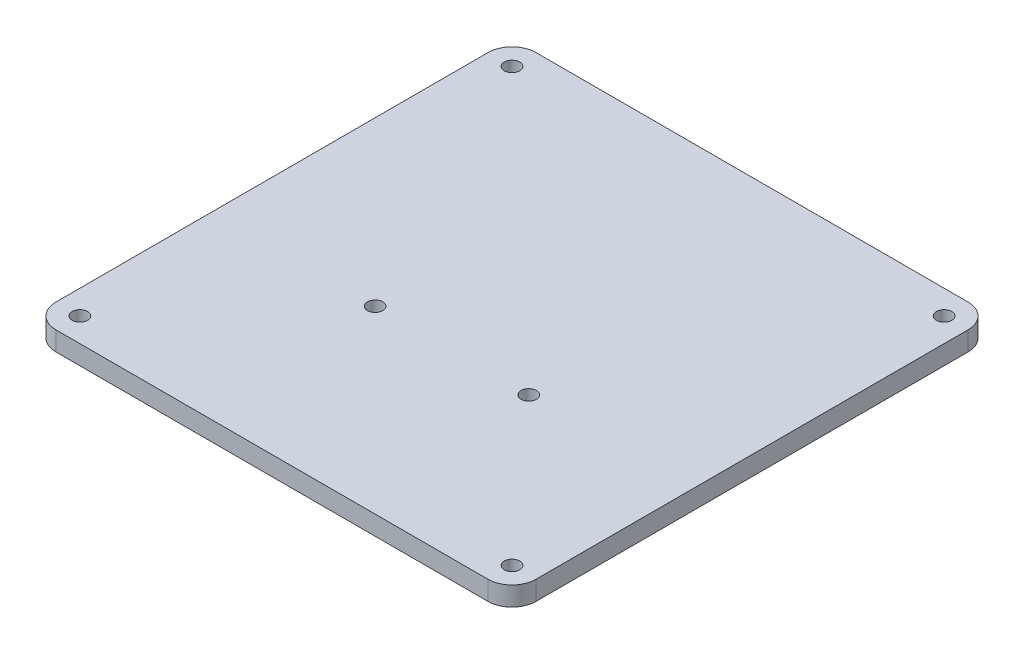
from build123d import *

# Parameters (mm, degrees)
SKETCH1_W           = 100
SKETCH1_H           = 100
SKETCH1_R           = 1.6
BOSS_EXTRUDE1_DEPTH = 4
FILLET1_R           = 5


with BuildPart() as part:
    # Sketch1 → Boss-Extrude1 (new body)
    with BuildSketch(Plane(origin=(0, 0, 0), x_dir=(1, 0, 0), z_dir=(0, 1, 0))):
        Rectangle(SKETCH1_W, SKETCH1_H)
        with Locations((-45, 45)):
            Circle(SKETCH1_R, mode=Mode.SUBTRACT)
        with Locations((45, 45)):
            Circle(SKETCH1_R, mode=Mode.SUBTRACT)
        with Locations((45, -45)):
            Circle(SKETCH1_R, mode=Mode.SUBTRACT)
        with Locations((-45, -45)):
            Circle(SKETCH1_R, mode=Mode.SUBTRACT)
        with Locations((16, -12.5)):
            Circle(SKETCH1_R, mode=Mode.SUBTRACT)
        with Locations((-16, -12.5)):
            Circle(SKETCH1_R, mode=Mode.SUBTRACT)
    extrude(amount=BOSS_EXTRUDE1_DEPTH)

    # Fillet1
    fillet1_edges = [part.edges().sort_by_distance(p)[0] for p in [
        (-50, 2, -50),
        (50, 2, -50),
        (50, 2, 50),
        (-50, 2, 50),
    ]]
    fillet(fillet1_edges, radius=FILLET1_R)


solid = part.part
